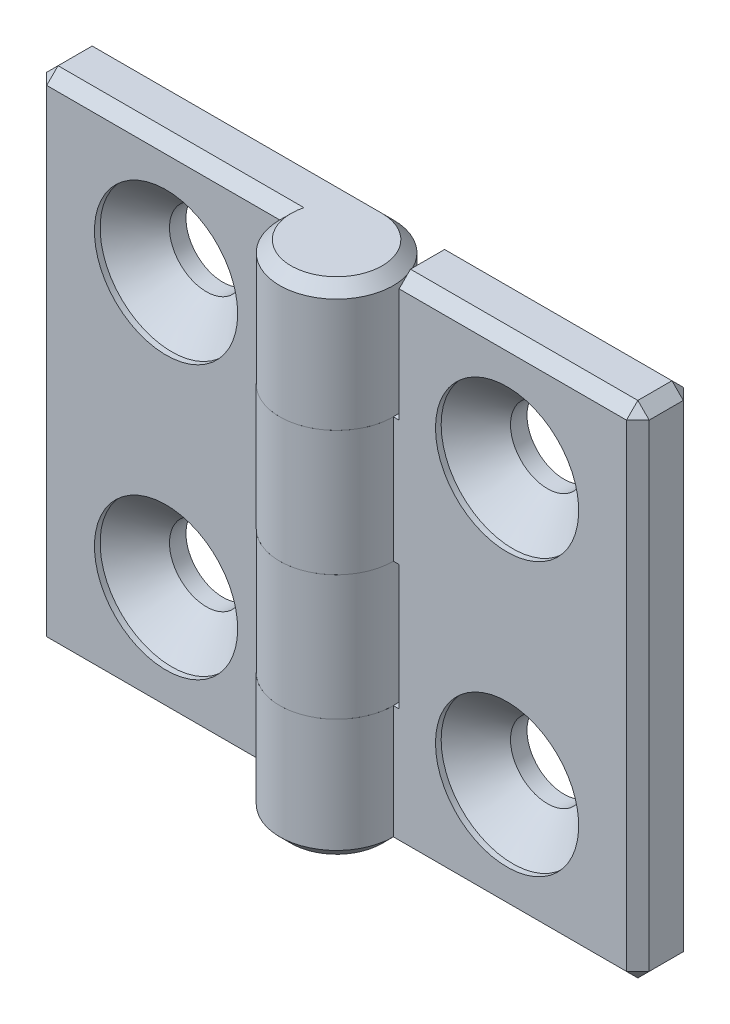
from build123d import *

# Parameters (mm, degrees)
EXTRUDE_1_DEPTH            = 22
SKETCH_3_W                 = 10.5
SKETCH_3_H                 = 11
CUT_EXTRUDE_1_DEPTH        = 6
CUT_EXTRUDE_1_DEPTH_BACK   = 6
HOLE_WIZARD_M61_AT_2_COUNT = 2
HOLE_WIZARD_M61_AT_2_PITCH = 24
CHAMFER_1_SIZE             = 1
PATTERN_CIRCULAR_1_COUNT   = 2


with BuildPart() as part:
    # Эскиз1 → Бобышка-Вытянуть1 (new body, symmetric)
    with BuildSketch(Plane(origin=(0, 0, 0), x_dir=(1, 0, 0), z_dir=(0, 1, 0))):
        with BuildLine():
            Line((0, 5), (-26.5, 5))
            Line((-26.5, 5), (-26.5, 0))
            Line((-26.5, 0), (-5, 0))
            ThreePointArc((-5, 0), (3.535533906, -3.535533906), (0, 5))
        make_face()
    extrude(amount=EXTRUDE_1_DEPTH, both=True)

    # Эскиз3 → Вырез-Вытянуть1 (cut, two sides)
    with BuildSketch(Plane.XY) as cut_extrude_1_sk:
        with Locations((-0.25, 5.5)):
            Rectangle(SKETCH_3_W, SKETCH_3_H)
        with Locations((-0.25, -16.5)):
            Rectangle(SKETCH_3_W, SKETCH_3_H)
    extrude(amount=CUT_EXTRUDE_1_DEPTH, mode=Mode.SUBTRACT)
    extrude(cut_extrude_1_sk.sketch, amount=-CUT_EXTRUDE_1_DEPTH_BACK, mode=Mode.SUBTRACT)

    # Эскиз6 → Зенковка для винта с полупотайной головкой M61 (revolve, cut)
    with BuildSketch(Plane(origin=(-15, 12, 0), x_dir=(0, -1, 0), z_dir=(1, 0, 0))):
        Polygon((0, 0), (0, 5), (3.25, 5), (3.25, 3.55), (6.3, 0.5), (6.3, 0), align=None)
    hole_wizard_m61 = revolve(axis=Axis((-15, 12, 6.35), (0, 0, -1)), mode=Mode.SUBTRACT)

    # Зенковка для винта с полупотайной головкой M61 at 2: Зенковка для винта с полупотайной головкой M61 ×2
    with Locations(*[(0, -i * HOLE_WIZARD_M61_AT_2_PITCH, 0) for i in range(1, HOLE_WIZARD_M61_AT_2_COUNT)]):
        add(hole_wizard_m61, mode=Mode.SUBTRACT)

    # Фаска1
    chamfer_1_edges = [part.edges().sort_by_distance(p)[0] for p in [
        (-26.5, 22, -2.5),
        (-16, -22, -5),
        (-15.75, 22, 0),
        (3.535533906, 22, 3.535533906),
        (-16, -22, 0),
        (-26.5, -22, -2.5),
        (-26.5, 0, 0),
        (-26.5, 0, -5),
        (-13.25, 22, -5),
    ]]
    chamfer(chamfer_1_edges, length=CHAMFER_1_SIZE)


with BuildPart() as pattern_circular_1_1:
    # Круговой массив1: pattern copy
    add(part.part.rotate(Axis((0, 0, 0), (0, 0, 1)), 1 * 360 / PATTERN_CIRCULAR_1_COUNT))


solid = Compound([part.part, pattern_circular_1_1.part])
